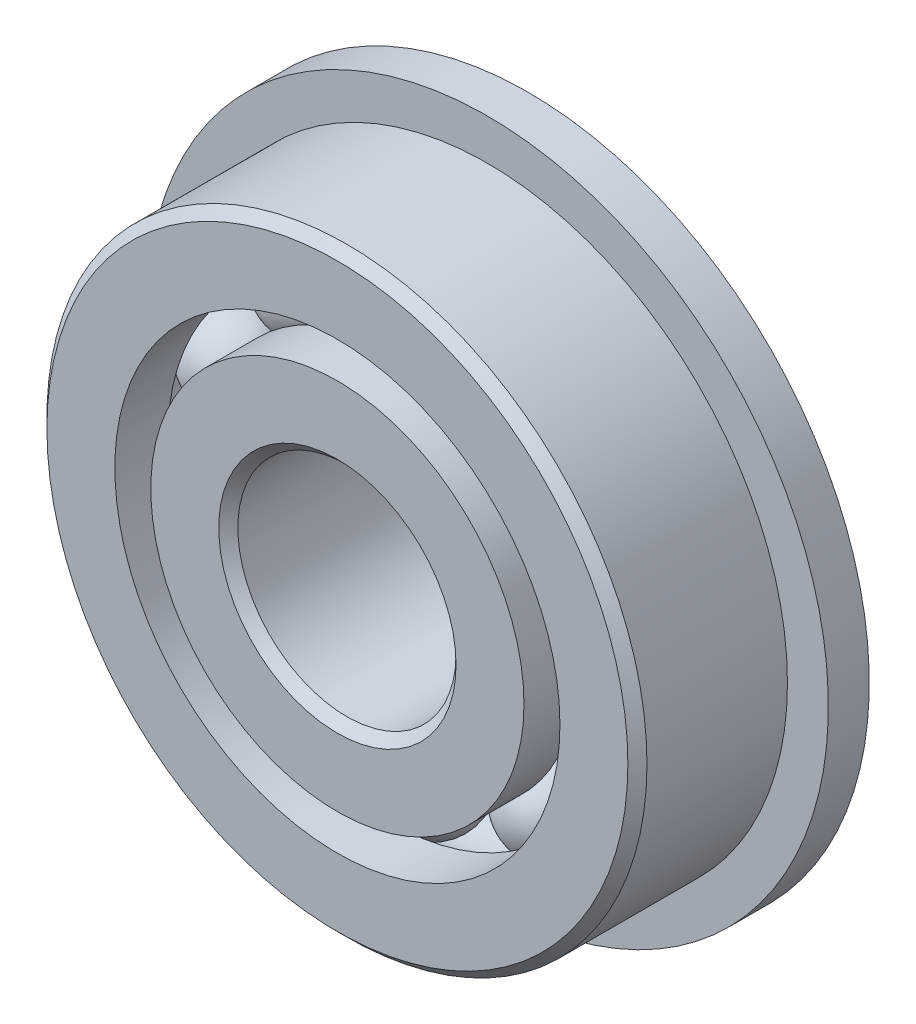
from build123d import *

# Parameters (mm, degrees)
CIRPATTERN1_COUNT = 10
SKETCH6_W         = 1.5
SKETCH6_H         = 4.340659341


with BuildPart() as part:
    # Sketch1 → Revolve1 (revolve)
    with BuildSketch(Plane(origin=(0, 0, 0), x_dir=(0, 0, -1), z_dir=(1, 0, 0))):
        with BuildLine():
            Line((3.15, 11), (-3.15, 11))
            Line((-3.15, 11), (-3.5, 10.65))
            Line((-3.5, 10.65), (-3.5, 8.159340659))
            Line((-3.5, 8.159340659), (-1.555555556, 8.159340659))
            ThreePointArc((-1.555555556, 8.159340659), (0, 9.189521587), (1.555555556, 8.159340659))
            Line((1.555555556, 8.159340659), (3.5, 8.159340659))
            Line((3.5, 8.159340659), (3.5, 10.65))
            Line((3.5, 10.65), (3.15, 11))
        make_face()
    revolve(axis=Axis((0, 0, 3.5), (0, 0, -1)))

    # Sketch6 → Revolve6 (revolve)
    with BuildSketch(Plane(origin=(0, 0, 0), x_dir=(0, 0, -1), z_dir=(1, 0, 0))):
        with Locations((2.75, 10.32967033)):
            Rectangle(SKETCH6_W, SKETCH6_H)
    revolve(axis=Axis((0, 0, -3.5), (0, 0, 1)))


with BuildPart() as body_2:
    # Sketch3 → Revolve3 (revolve)
    with BuildSketch(Plane(origin=(0, 0, 0), x_dir=(0, 0, -1), z_dir=(1, 0, 0))):
        with BuildLine():
            Line((-3.5, 6.840659341), (-1.555555556, 6.840659341))
            ThreePointArc((-1.555555556, 6.840659341), (0, 5.810478413), (1.555555556, 6.840659341))
            Line((1.555555556, 6.840659341), (3.5, 6.840659341))
            Line((3.5, 6.840659341), (3.5, 4.35))
            Line((3.5, 4.35), (3.15, 4))
            Line((3.15, 4), (-3.15, 4))
            Line((-3.15, 4), (-3.5, 4.35))
            Line((-3.5, 4.35), (-3.5, 6.840659341))
        make_face()
    revolve(axis=Axis((0, 0, 3.5), (0, 0, -1)))


with BuildPart() as body_3:
    # Sketch4 → Revolve4 (revolve)
    with BuildSketch(Plane(origin=(0, 0, 0), x_dir=(0, 0, -1), z_dir=(1, 0, 0))):
        with BuildLine():
            Line((-1.689521587, 7.5), (1.689521587, 7.5))
            ThreePointArc((1.689521587, 7.5), (0, 9.189521587), (-1.689521587, 7.5))
        make_face()
    revolve(axis=Axis((0, 7.5, 1.689521587), (0, 0, -1)))


with BuildPart() as cirpattern1_1:
    # CirPattern1: pattern copy
    add(body_3.part.rotate(Axis((0, 0, -3.5), (0, 0, 1)), 1 * 360 / CIRPATTERN1_COUNT))


with BuildPart() as cirpattern1_2:
    # CirPattern1: pattern copy
    add(body_3.part.rotate(Axis((0, 0, -3.5), (0, 0, 1)), 2 * 360 / CIRPATTERN1_COUNT))


with BuildPart() as cirpattern1_3:
    # CirPattern1: pattern copy
    add(body_3.part.rotate(Axis((0, 0, -3.5), (0, 0, 1)), 3 * 360 / CIRPATTERN1_COUNT))


with BuildPart() as cirpattern1_4:
    # CirPattern1: pattern copy
    add(body_3.part.rotate(Axis((0, 0, -3.5), (0, 0, 1)), 4 * 360 / CIRPATTERN1_COUNT))


with BuildPart() as cirpattern1_5:
    # CirPattern1: pattern copy
    add(body_3.part.rotate(Axis((0, 0, -3.5), (0, 0, 1)), 5 * 360 / CIRPATTERN1_COUNT))


with BuildPart() as cirpattern1_6:
    # CirPattern1: pattern copy
    add(body_3.part.rotate(Axis((0, 0, -3.5), (0, 0, 1)), 6 * 360 / CIRPATTERN1_COUNT))


with BuildPart() as cirpattern1_7:
    # CirPattern1: pattern copy
    add(body_3.part.rotate(Axis((0, 0, -3.5), (0, 0, 1)), 7 * 360 / CIRPATTERN1_COUNT))


with BuildPart() as cirpattern1_8:
    # CirPattern1: pattern copy
    add(body_3.part.rotate(Axis((0, 0, -3.5), (0, 0, 1)), 8 * 360 / CIRPATTERN1_COUNT))


with BuildPart() as cirpattern1_9:
    # CirPattern1: pattern copy
    add(body_3.part.rotate(Axis((0, 0, -3.5), (0, 0, 1)), 9 * 360 / CIRPATTERN1_COUNT))


solid = Compound([part.part, body_2.part, body_3.part, cirpattern1_1.part, cirpattern1_2.part, cirpattern1_3.part, cirpattern1_4.part, cirpattern1_5.part, cirpattern1_6.part, cirpattern1_7.part, cirpattern1_8.part, cirpattern1_9.part])
